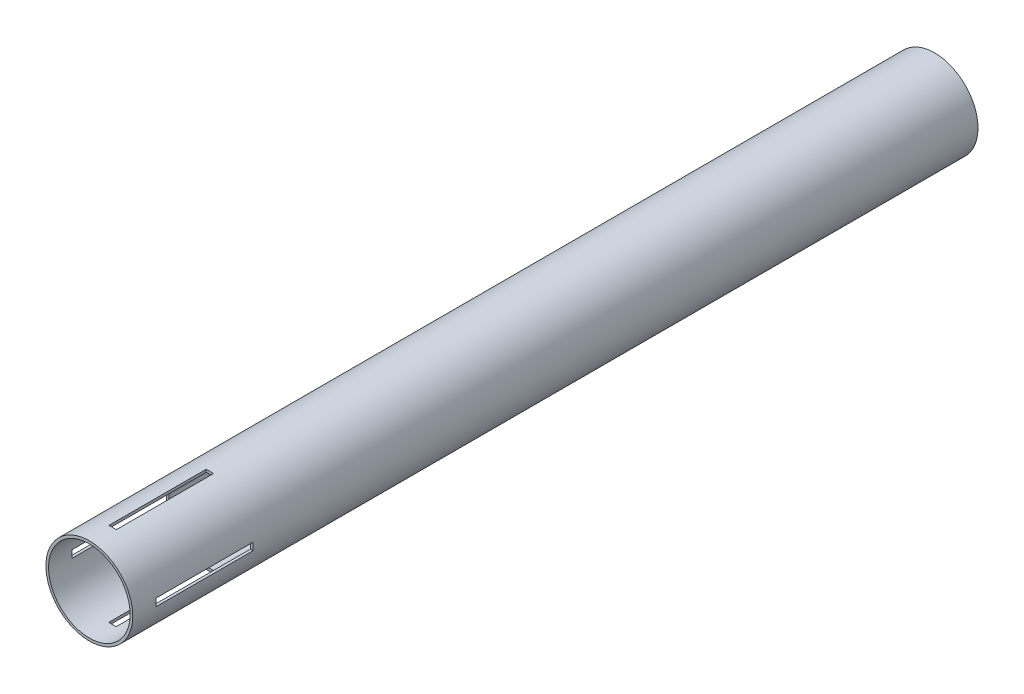
from build123d import *

# Parameters (mm, degrees)
SKETCH1_R           = 20.555
SKETCH1_R_2         = 19.305
BOSS_EXTRUDE3_DEPTH = 400
SKETCH2_W           = 3.5
SKETCH2_H           = 46
CUT_EXTRUDE1_DEPTH  = 21.555
CIRPATTERN1_COUNT   = 2
CIRPATTERN1_ANGLE   = 90


with BuildPart() as part:
    # Sketch1 → Boss-Extrude3 (new body)
    with BuildSketch(Plane.XY):
        Circle(SKETCH1_R)
        Circle(SKETCH1_R_2, mode=Mode.SUBTRACT)
    extrude(amount=-BOSS_EXTRUDE3_DEPTH)

    # Sketch2 → Cut-Extrude1 (cut, symmetric)
    with BuildSketch(Plane(origin=(0, 0, 0), x_dir=(1, 0, 0), z_dir=(0, 1, 0))):
        with Locations((0, 34)):
            Rectangle(SKETCH2_W, SKETCH2_H)
    cut_extrude1 = extrude(amount=CUT_EXTRUDE1_DEPTH, both=True, mode=Mode.SUBTRACT)

    # CirPattern1: Cut-Extrude1 ×2 about axis
    cirpattern1_axis = Axis((0, 0, -400), (0, 0, 1))
    for i in range(1, CIRPATTERN1_COUNT):
        add(cut_extrude1.rotate(cirpattern1_axis, i * CIRPATTERN1_ANGLE / (CIRPATTERN1_COUNT - 1)), mode=Mode.SUBTRACT)


solid = part.part
